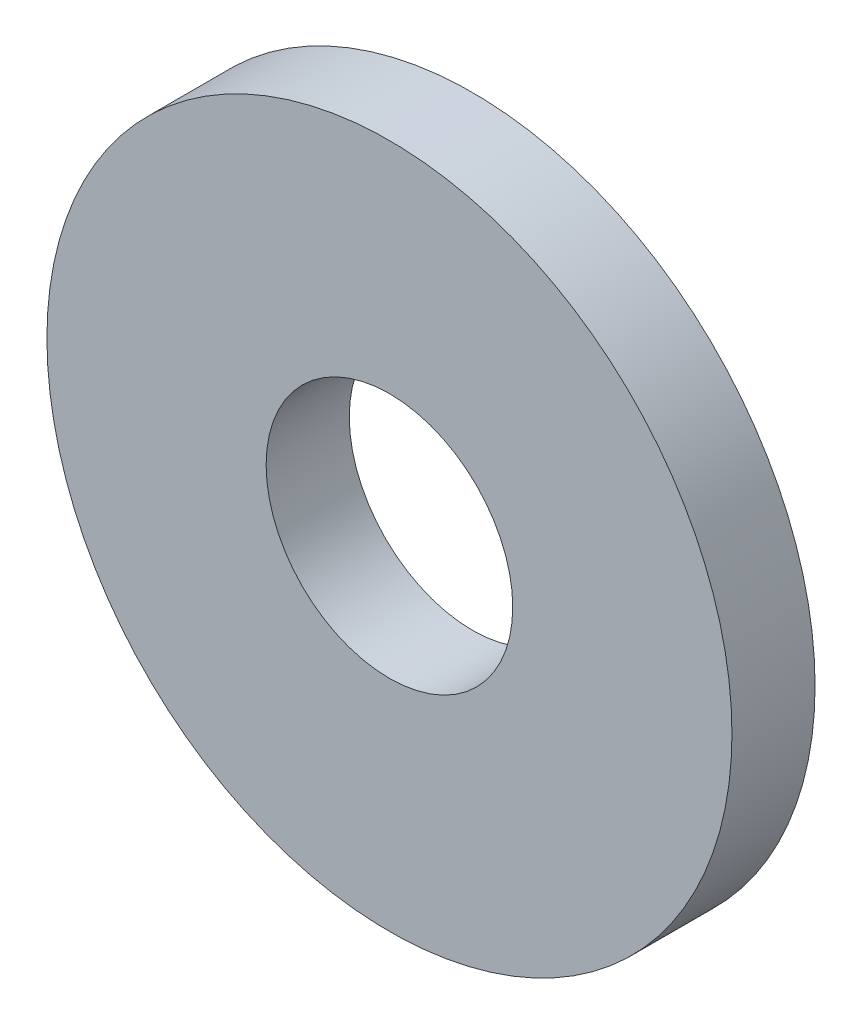
from build123d import *

# Parameters (mm, degrees)
SKETCH1_R           = 9.525
SKETCH1_R_2         = 3.429
BOSS_EXTRUDE1_DEPTH = 2.3114


with BuildPart() as part:
    # Sketch1 → Boss-Extrude1 (new body)
    with BuildSketch(Plane.XY):
        Circle(SKETCH1_R)
        Circle(SKETCH1_R_2, mode=Mode.SUBTRACT)
    extrude(amount=BOSS_EXTRUDE1_DEPTH)


solid = part.part
